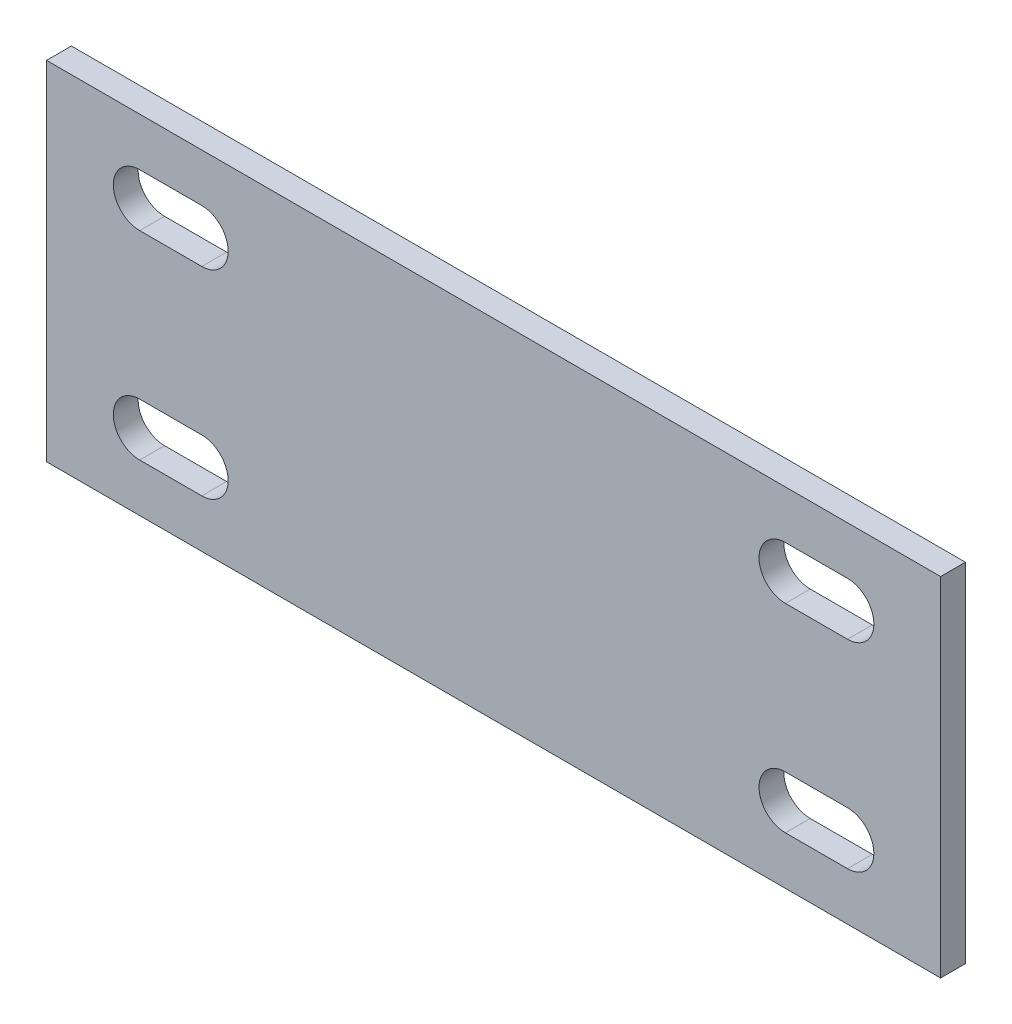
from build123d import *

# Parameters (mm, degrees)
SKETCH1_W           = 228.6
SKETCH1_H           = 88.9
BOSS_EXTRUDE1_DEPTH = 6.35
CUT_EXTRUDE1_DEPTH  = 7.35
LPATTERN1_COUNT     = 2
LPATTERN1_PITCH     = 165.1


with BuildPart() as part:
    # Sketch1 → Boss-Extrude1 (new body)
    with BuildSketch(Plane.XY):
        with Locations((114.3, 44.45)):
            Rectangle(SKETCH1_W, SKETCH1_H)
    extrude(amount=BOSS_EXTRUDE1_DEPTH)

    # Sketch2 → Cut-Extrude1 (cut, through all)
    with BuildSketch(Plane.XY.offset(6.35)):
        with BuildLine():
            Line((23.8125, 76.5937), (39.6875, 76.5937))
            ThreePointArc((39.6875, 76.5937), (46.4312, 69.85), (39.6875, 63.1063))
            Line((39.6875, 63.1063), (23.8125, 63.1063))
            ThreePointArc((23.8125, 63.1063), (17.0688, 69.85), (23.8125, 76.5937))
        make_face()
        with BuildLine():
            Line((23.8125, 25.7937), (39.6875, 25.7937))
            ThreePointArc((39.6875, 25.7937), (46.4312, 19.05), (39.6875, 12.3063))
            Line((39.6875, 12.3063), (23.8125, 12.3063))
            ThreePointArc((23.8125, 12.3063), (17.0688, 19.05), (23.8125, 25.7937))
        make_face()
    cut_extrude1 = extrude(amount=-CUT_EXTRUDE1_DEPTH, mode=Mode.SUBTRACT)

    # LPattern1: Cut-Extrude1 ×2
    with Locations(*[(i * LPATTERN1_PITCH, 0, 0) for i in range(1, LPATTERN1_COUNT)]):
        add(cut_extrude1, mode=Mode.SUBTRACT)


solid = part.part
